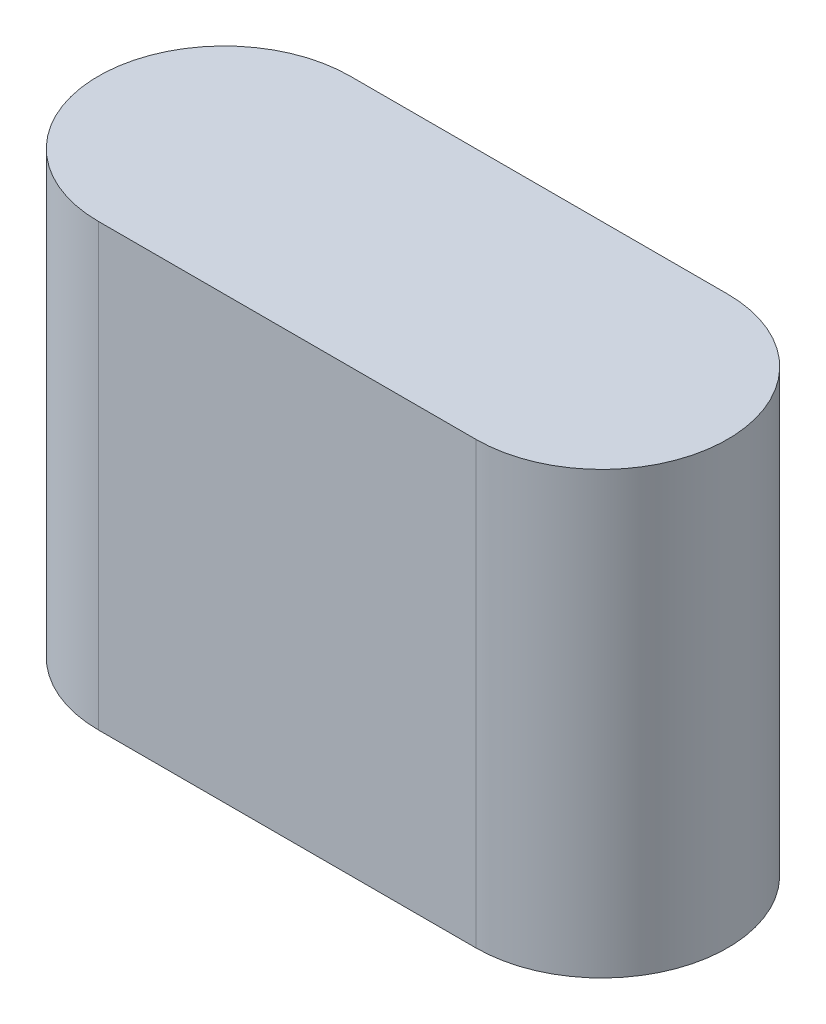
from build123d import *

# Parameters (mm, degrees)
EXTRUDE_1_DEPTH = 35


with BuildPart() as part:
    # 스케치1 → 보스-돌출1 (new body)
    with BuildSketch(Plane(origin=(0, 0, 0), x_dir=(1, 0, 0), z_dir=(0, 1, 0))):
        with BuildLine():
            Line((-11.924686192, 10), (18.075313808, 10))
            ThreePointArc((18.075313808, 10), (28.075313808, 0), (18.075313808, -10))
            Line((18.075313808, -10), (-11.924686192, -10))
            ThreePointArc((-11.924686192, -10), (-21.924686192, 0), (-11.924686192, 10))
        make_face()
    extrude(amount=EXTRUDE_1_DEPTH)


solid = part.part
